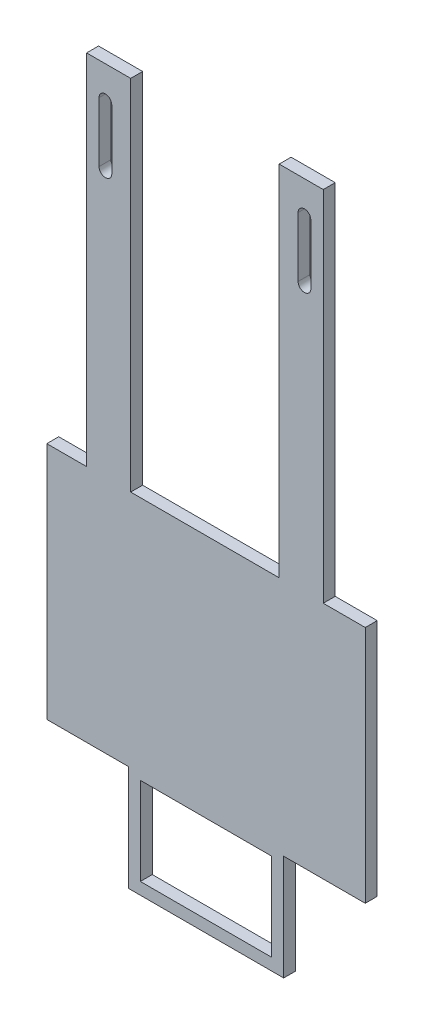
from build123d import *

# Parameters (mm, degrees)
SKETCH_1_W      = 33
SKETCH_1_H      = 22
EXTRUDE_1_DEPTH = 3


with BuildPart() as part:
    # 草图1 → 凸台-拉伸1 (new body)
    with BuildSketch(Plane.XY):
        Polygon((12.097999847, 68.896913641), (23.174949538, 68.896913641), (23.174949538, -21.103086359), (33.727403861, -21.103086359), (33.727403861, -81.103086359), (13.227403861, -81.103086359), (13.227403861, -107.603086359), (-25.772596139, -107.603086359), (-25.772596139, -81.103086359), (-46.272596139, -81.103086359), (-46.272596139, -21.103086359), (-36.272596139, -21.103086359), (-36.272596139, 68.896913641), (-25.195646449, 68.896913641), (-25.195646449, -21.103086359), (12.097999847, -21.103086359), align=None)
        with BuildLine():
            Line((-33.148823301, 45.73159086), (-33.148823301, 60.73159086))
            ThreePointArc((-33.148823301, 60.73159086), (-31.548823301, 62.33159086), (-29.948823301, 60.73159086))
            Line((-29.948823301, 60.73159086), (-29.948823301, 45.73159086))
            ThreePointArc((-29.948823301, 45.73159086), (-31.548823301, 44.13159086), (-33.148823301, 45.73159086))
        make_face(mode=Mode.SUBTRACT)
        with BuildLine():
            Line((20.051176699, 45.73159086), (20.051176699, 60.73159086))
            ThreePointArc((20.051176699, 60.73159086), (18.451176699, 62.33159086), (16.851176699, 60.73159086))
            Line((16.851176699, 60.73159086), (16.851176699, 45.73159086))
            ThreePointArc((16.851176699, 45.73159086), (18.451176699, 44.13159086), (20.051176699, 45.73159086))
        make_face(mode=Mode.SUBTRACT)
        with Locations((-6.272596139, -93.603086359)):
            Rectangle(SKETCH_1_W, SKETCH_1_H, mode=Mode.SUBTRACT)
    extrude(amount=EXTRUDE_1_DEPTH)


solid = part.part
